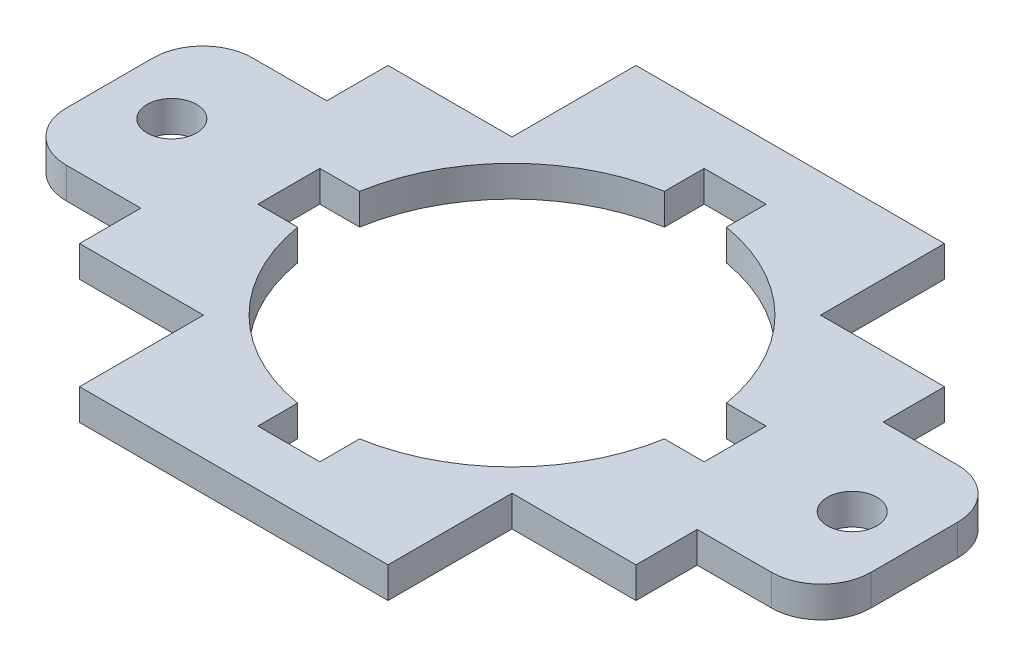
from build123d import *

# Parameters (mm, degrees)
SKETCH1_R           = 2.54
BOSS_EXTRUDE1_DEPTH = 3.175


with BuildPart() as part:
    # Sketch1 → Boss-Extrude1 (new body)
    with BuildSketch(Plane(origin=(0, 0, 0), x_dir=(1, 0, 0), z_dir=(0, 1, 0))):
        with BuildLine():
            Line((15.7999938, -28.4999938), (-15.7999938, -28.4999938))
            Line((-15.7999938, -28.4999938), (-15.7999938, -15.7999938))
            Line((-15.7999938, -15.7999938), (-28.4999938, -15.7999938))
            Line((-28.4999938, -15.7999938), (-28.4999938, -9.525))
            Line((-28.4999938, -9.525), (-36.1199938, -9.525))
            ThreePointArc((-36.1199938, -9.525), (-39.712096248, -8.037102448), (-41.1999938, -4.445))
            Line((-41.1999938, -4.445), (-41.1999938, 4.445))
            ThreePointArc((-41.1999938, 4.445), (-39.712096248, 8.037102448), (-36.1199938, 9.525))
            Line((-36.1199938, 9.525), (-28.4999938, 9.525))
            Line((-28.4999938, 9.525), (-28.4999938, 15.7999938))
            Line((-28.4999938, 15.7999938), (-15.7999938, 15.7999938))
            Line((-15.7999938, 15.7999938), (-15.7999938, 28.4999938))
            Line((-15.7999938, 28.4999938), (15.7999938, 28.4999938))
            Line((15.7999938, 28.4999938), (15.7999938, 15.7999938))
            Line((15.7999938, 15.7999938), (28.4999938, 15.7999938))
            Line((28.4999938, 15.7999938), (28.4999938, 9.525))
            Line((28.4999938, 9.525), (36.1199938, 9.525))
            ThreePointArc((36.1199938, 9.525), (39.712096248, 8.037102448), (41.1999938, 4.445))
            Line((41.1999938, 4.445), (41.1999938, -4.445))
            ThreePointArc((41.1999938, -4.445), (39.712096248, -8.037102448), (36.1199938, -9.525))
            Line((36.1199938, -9.525), (28.4999938, -9.525))
            Line((28.4999938, -9.525), (28.4999938, -15.7999938))
            Line((28.4999938, -15.7999938), (15.7999938, -15.7999938))
            Line((15.7999938, -15.7999938), (15.7999938, -28.4999938))
        make_face()
        with Locations((-34.8499938, 0)):
            Circle(SKETCH1_R, mode=Mode.SUBTRACT)
        with Locations((34.8499938, 0)):
            Circle(SKETCH1_R, mode=Mode.SUBTRACT)
        with BuildLine():
            Line((-18.783553311, 3.175), (-22.86, 3.175))
            Line((-22.86, 3.175), (-22.86, -3.175))
            Line((-22.86, -3.175), (-18.783553311, -3.175))
            ThreePointArc((-18.783553311, -3.175), (-13.470384182, -13.470384182), (-3.175, -18.783553311))
            Line((-3.175, -18.783553311), (-3.175, -22.86))
            Line((-3.175, -22.86), (3.175, -22.86))
            Line((3.175, -22.86), (3.175, -18.783553311))
            ThreePointArc((3.175, -18.783553311), (13.470384182, -13.470384182), (18.783553311, -3.175))
            Line((18.783553311, -3.175), (22.86, -3.175))
            Line((22.86, -3.175), (22.86, 3.175))
            Line((22.86, 3.175), (18.783553311, 3.175))
            ThreePointArc((18.783553311, 3.175), (13.470384182, 13.470384182), (3.175, 18.783553311))
            Line((3.175, 18.783553311), (3.175, 22.86))
            Line((3.175, 22.86), (-3.175, 22.86))
            Line((-3.175, 22.86), (-3.175, 18.783553311))
            ThreePointArc((-3.175, 18.783553311), (-13.470384182, 13.470384182), (-18.783553311, 3.175))
        make_face(mode=Mode.SUBTRACT)
    extrude(amount=BOSS_EXTRUDE1_DEPTH)


solid = part.part
